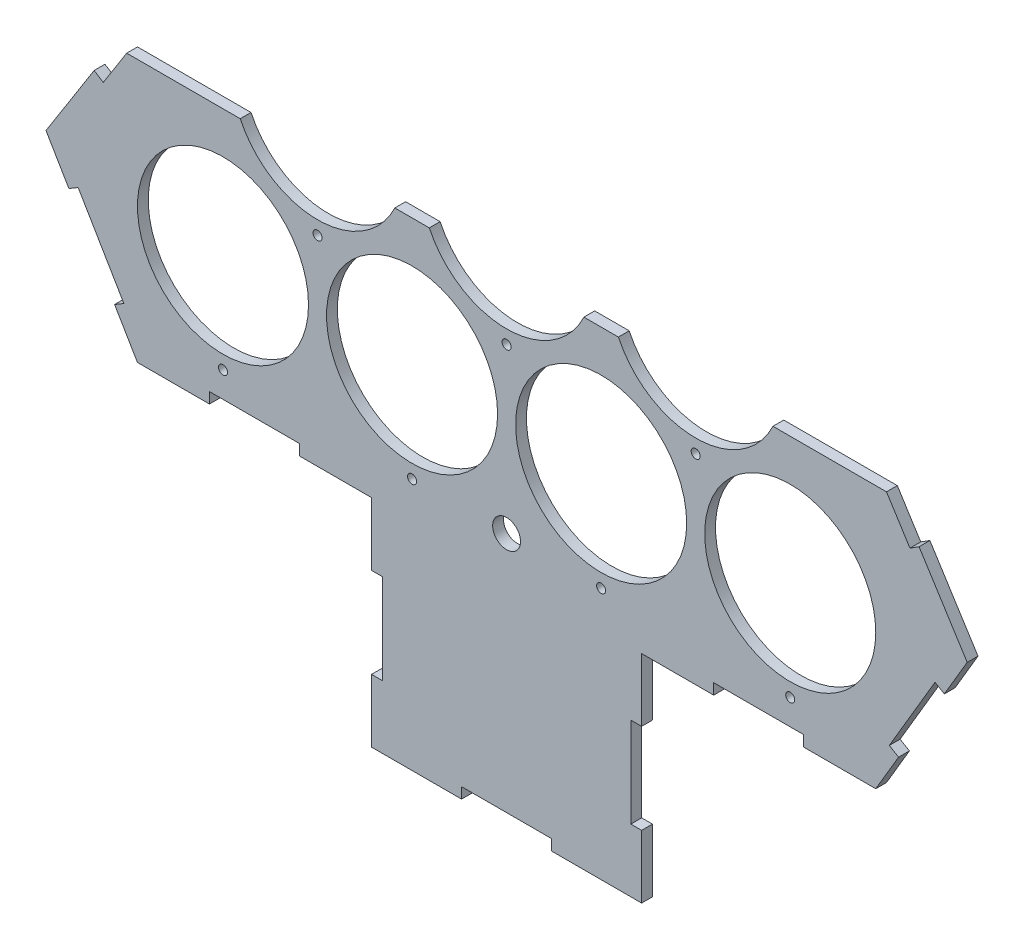
from build123d import *

# Parameters (mm, degrees)
ESQUISSE1_R             = 47.5
BOSS_EXTRU_1_DEPTH      = 6
ESQUISSE9_W             = 150
ESQUISSE9_H             = 120
BOSS_EXTRU_2_DEPTH      = 6
ESQUISSE10_W            = 6
ESQUISSE10_H            = 50
ESQUISSE10_W_2          = 50
ESQUISSE10_H_2          = 6
ENL_V_MAT_EXTRU_1_DEPTH = 10
ESQUISSE12_W            = 675.538278175
ESQUISSE12_H            = 265.771999275
ENL_V_MAT_EXTRU_3_DEPTH = 10
ESQUISSE13_R            = 2.5
ENL_V_MAT_EXTRU_4_DEPTH = 10
ESQUISSE14_R            = 7.75
ENL_V_MAT_EXTRU_5_DEPTH = 10


with BuildPart() as part:
    # Esquisse1 → Boss.-Extru.1 (new body)
    with BuildSketch(Plane.XY):
        Polygon((-255.775862069, 10.959681362), (-205, -75.190256718), (205, -75.190256718), (255.775862069, 10.959681362), (50, 336.353741833), (-50, 336.353741833), align=None)
        with Locations((-157.5, 0)):
            Circle(ESQUISSE1_R, mode=Mode.SUBTRACT)
        with Locations((-52.5, 0)):
            Circle(ESQUISSE1_R, mode=Mode.SUBTRACT)
        with Locations((52.5, 0)):
            Circle(ESQUISSE1_R, mode=Mode.SUBTRACT)
        with Locations((157.5, 0)):
            Circle(ESQUISSE1_R, mode=Mode.SUBTRACT)
        with Locations((-105, 90.932667397)):
            Circle(ESQUISSE1_R, mode=Mode.SUBTRACT)
        with Locations((0, 90.932667397)):
            Circle(ESQUISSE1_R, mode=Mode.SUBTRACT)
        with Locations((105, 90.932667397)):
            Circle(ESQUISSE1_R, mode=Mode.SUBTRACT)
        with Locations((-52.5, 181.865334795)):
            Circle(ESQUISSE1_R, mode=Mode.SUBTRACT)
        with Locations((52.5, 181.865334795)):
            Circle(ESQUISSE1_R, mode=Mode.SUBTRACT)
        with Locations((0, 272.798002192)):
            Circle(ESQUISSE1_R, mode=Mode.SUBTRACT)
    extrude(amount=BOSS_EXTRU_1_DEPTH)

    # Esquisse9 → Boss.-Extru.2 (add)
    with BuildSketch(Plane.XY.offset(6)):
        with Locations((0, -135.190256718)):
            Rectangle(ESQUISSE9_W, ESQUISSE9_H)
    extrude(amount=-BOSS_EXTRU_2_DEPTH)

    # Esquisse10 → Enlèv. mat.-Extru.1 (cut)
    with BuildSketch(Plane.XY.offset(6)):
        with Locations((-72, -135.190256718)):
            Rectangle(ESQUISSE10_W, ESQUISSE10_H)
        with Locations((0, -192.190256718)):
            Rectangle(ESQUISSE10_W_2, ESQUISSE10_H_2)
        with Locations((-140, -72.190256718)):
            Rectangle(ESQUISSE10_W_2, ESQUISSE10_H_2)
        Polygon((-217.693965517, -53.652772198), (-212.524969232, -50.606220473), (-237.912900267, -7.531251434), (-243.081896552, -10.577803158), align=None)
        Polygon((-229.051724138, 53.218650255), (-223.980647871, 50.011753703), (-170.532372009, 134.529691487), (-175.603448276, 137.736588039), align=None)
        Polygon((-130.172413793, 209.576835156), (-125.101337526, 206.369938604), (-71.653061664, 290.887876389), (-76.724137931, 294.094772941), align=None)
        with Locations((0, 333.353741833)):
            Rectangle(ESQUISSE10_W_2, ESQUISSE10_H_2)
        Polygon((71.653061664, 290.887876389), (76.724137931, 294.094772941), (130.172413793, 209.576835156), (125.101337526, 206.369938604), align=None)
        Polygon((170.532372009, 134.529691487), (175.603448276, 137.736588039), (229.051724138, 53.218650255), (223.980647871, 50.011753703), align=None)
        Polygon((237.912900267, -7.531251434), (243.081896552, -10.577803158), (217.693965517, -53.652772198), (212.524969232, -50.606220473), align=None)
        with Locations((140, -72.190256718)):
            Rectangle(ESQUISSE10_W_2, ESQUISSE10_H_2)
        with Locations((72, -135.190256718)):
            Rectangle(ESQUISSE10_W, ESQUISSE10_H)
    extrude(amount=-ENL_V_MAT_EXTRU_1_DEPTH, mode=Mode.SUBTRACT)

    # Esquisse12 → Enlèv. mat.-Extru.3 (cut)
    with BuildSketch(Plane.XY.offset(6)):
        with Locations((-8.823645222, 203.467742196)):
            Rectangle(ESQUISSE12_W, ESQUISSE12_H)
    extrude(amount=-ENL_V_MAT_EXTRU_3_DEPTH, mode=Mode.SUBTRACT)

    # Esquisse13 → Enlèv. mat.-Extru.4 (cut)
    with BuildSketch(Plane.XY.offset(6)):
        with Locations((-157.5, -55)):
            Circle(ESQUISSE13_R)
        with Locations((-52.5, -55)):
            Circle(ESQUISSE13_R)
        with Locations((52.5, -55)):
            Circle(ESQUISSE13_R)
        with Locations((157.5, -55)):
            Circle(ESQUISSE13_R)
        with Locations((-105, 35.932667397)):
            Circle(ESQUISSE13_R)
        with Locations((0, 35.932667397)):
            Circle(ESQUISSE13_R)
        with Locations((105, 35.932667397)):
            Circle(ESQUISSE13_R)
    extrude(amount=-ENL_V_MAT_EXTRU_4_DEPTH, mode=Mode.SUBTRACT)

    # Esquisse14 → Enlèv. mat.-Extru.5 (cut)
    with BuildSketch(Plane.XY.offset(6)):
        with Locations((0, -55)):
            Circle(ESQUISSE14_R)
    extrude(amount=-ENL_V_MAT_EXTRU_5_DEPTH, mode=Mode.SUBTRACT)


solid = part.part
